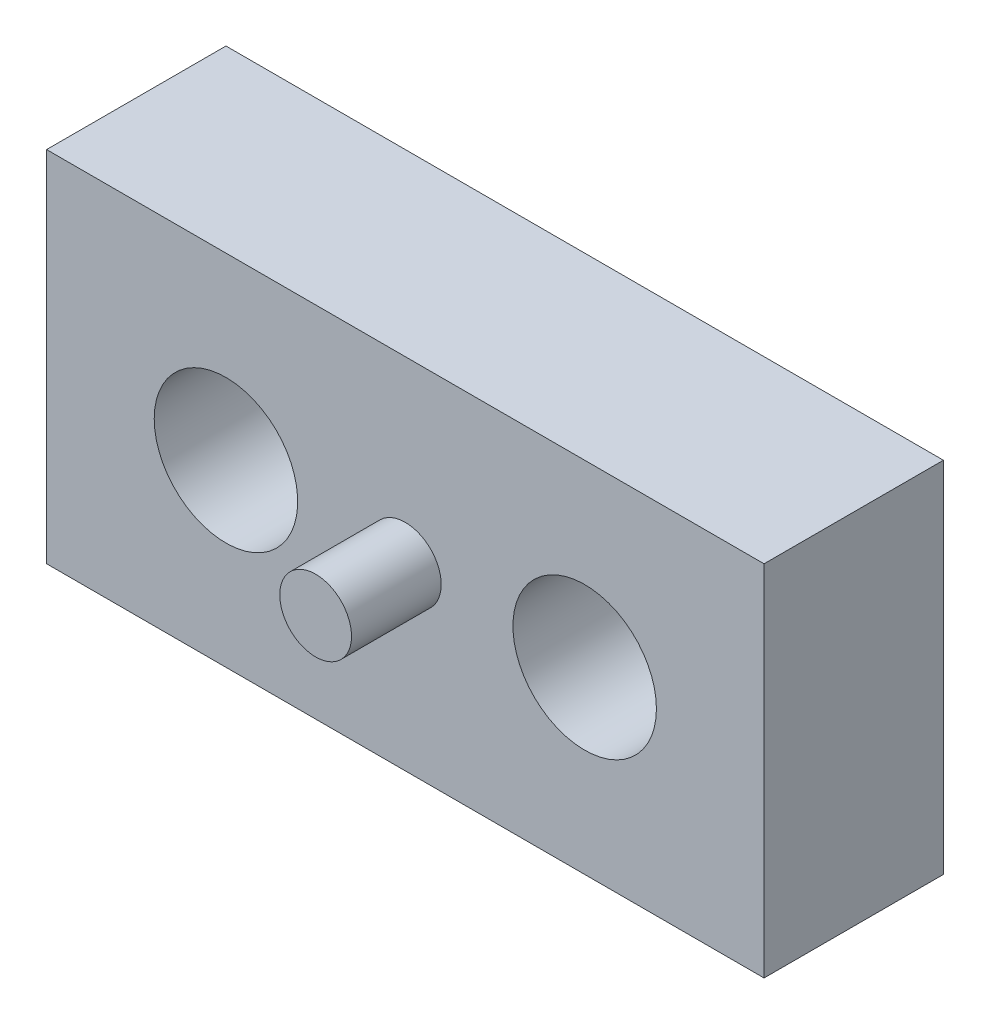
from build123d import *

# Parameters (mm, degrees)
SKETCH_1_W          = 20
SKETCH_1_H          = 10
SKETCH_1_R          = 1
EXTRUDE_1_DEPTH     = 5
SKETCH_2_R          = 1
EXTRUDE_2_DEPTH     = 2.5
SKETCH_4_R          = 2
CUT_EXTRUDE_2_DEPTH = 3


with BuildPart() as part:
    # 草图1 → 凸台-拉伸1 (new body)
    with BuildSketch(Plane.XY):
        Rectangle(SKETCH_1_W, SKETCH_1_H)
        with Locations((-5, 0)):
            Circle(SKETCH_1_R, mode=Mode.SUBTRACT)
        with Locations((5, 0)):
            Circle(SKETCH_1_R, mode=Mode.SUBTRACT)
    extrude(amount=EXTRUDE_1_DEPTH)

    # 草图2 → 凸台-拉伸2 (add)
    with BuildSketch(Plane.XY.offset(5)):
        Circle(SKETCH_2_R)
    extrude(amount=EXTRUDE_2_DEPTH)

    # 草图4 → 切除-拉伸2 (cut)
    with BuildSketch(Plane.XY.offset(5)):
        with Locations((5, 0)):
            Circle(SKETCH_4_R)
        with Locations((-5, 0)):
            Circle(SKETCH_4_R)
    extrude(amount=-CUT_EXTRUDE_2_DEPTH, mode=Mode.SUBTRACT)


solid = part.part
